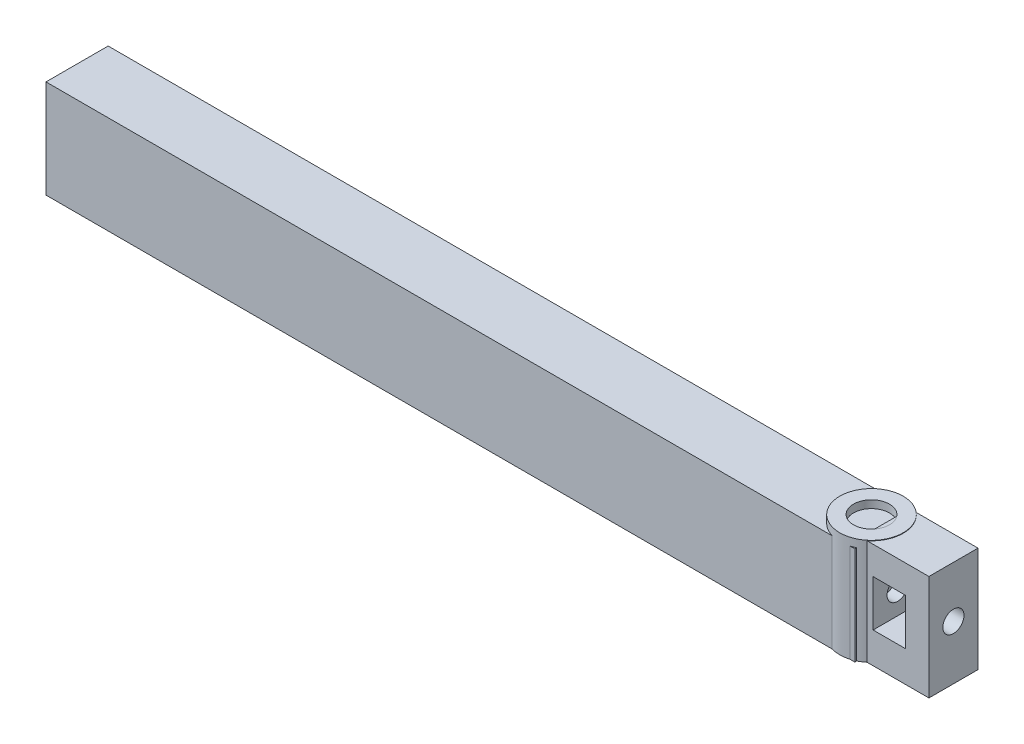
from build123d import *

# Parameters (mm, degrees)
SKETCH1_R               = 6
BOSS_EXTRUDE1_DEPTH     = 20
SKETCH2_R               = 3.4
CUT_EXTRUDE1_DEPTH      = 13.55
SKETCH5_W               = 1.550685087
SKETCH5_H               = 7.184215806
BOSS_EXTRUDE2_DEPTH     = 13.55
SKETCH7_W               = 9.286501956
SKETCH7_H               = 19.909960041
BOSS_EXTRUDE3_DEPTH     = 12.9
CUT_EXTRUDE2_DEPTH      = 1
CUT_EXTRUDE2_DEPTH_BACK = 13.55
SKETCH6_R               = 2
CUT_EXTRUDE3_DEPTH      = 10
CUT_EXTRUDE3_DEPTH_BACK = 10
SKETCH11_W              = 11.756176319
SKETCH11_H              = 18.551417714
BOSS_EXTRUDE4_DEPTH     = 153


with BuildPart() as part:
    # Sketch1 → Boss-Extrude1 (new body)
    with BuildSketch(Plane(origin=(0, 0, 0), x_dir=(1, 0, 0), z_dir=(0, 1, 0))):
        Circle(SKETCH1_R)
    extrude(amount=BOSS_EXTRUDE1_DEPTH)

    # Sketch2 → Cut-Extrude1 (cut)
    with BuildSketch(Plane(origin=(0, 20, 0), x_dir=(1, 0, 0), z_dir=(0, 1, 0))):
        Circle(SKETCH2_R)
    extrude(amount=-CUT_EXTRUDE1_DEPTH, mode=Mode.SUBTRACT)

    # Sketch5 → Boss-Extrude2 (add)
    with BuildSketch(Plane(origin=(0, 18.26, 0), x_dir=(1, 0, 0), z_dir=(0, 1, 0))):
        with Locations((3.375342544, 0.020519704)):
            Rectangle(SKETCH5_W, SKETCH5_H)
    extrude(amount=-BOSS_EXTRUDE2_DEPTH)

    # Sketch7 → Boss-Extrude3 (add)
    with BuildSketch(Plane.ZY.offset(-2.6)):
        with Locations((-0.005218197, 9.954980021)):
            Rectangle(SKETCH7_W, SKETCH7_H)
    extrude(amount=-BOSS_EXTRUDE3_DEPTH)

    # Sketch6 → Cut-Extrude2 (cut, two sides: drawn at the far end of the back side and taken through both)
    with BuildSketch(Plane.ZY.offset(-2.6).offset(-CUT_EXTRUDE2_DEPTH_BACK)):
        with Locations((0, 10.236925537)):
            Circle(SKETCH6_R)
    extrude(amount=CUT_EXTRUDE2_DEPTH + CUT_EXTRUDE2_DEPTH_BACK, mode=Mode.SUBTRACT)

    # Sketch9 → Cut-Extrude3 (cut, two sides: drawn at the far end of the back side and taken through both)
    with BuildSketch(Plane.XY.offset(-CUT_EXTRUDE3_DEPTH_BACK)):
        Polygon((11.063430227, 10.236925537), (11.063430227, 5.861925537), (4.943430227, 5.861925537), (4.943430227, 10.236925537), (4.943430227, 14.611925537), (11.063430227, 14.611925537), align=None)
    extrude(amount=CUT_EXTRUDE3_DEPTH + CUT_EXTRUDE3_DEPTH_BACK, mode=Mode.SUBTRACT)

    # Sketch11 → Boss-Extrude4 (add)
    with BuildSketch(Plane.ZY.offset(-2.6)):
        with Locations((-0.114099009, 9.275708857)):
            Rectangle(SKETCH11_W, SKETCH11_H)
    extrude(amount=BOSS_EXTRUDE4_DEPTH)


solid = part.part
